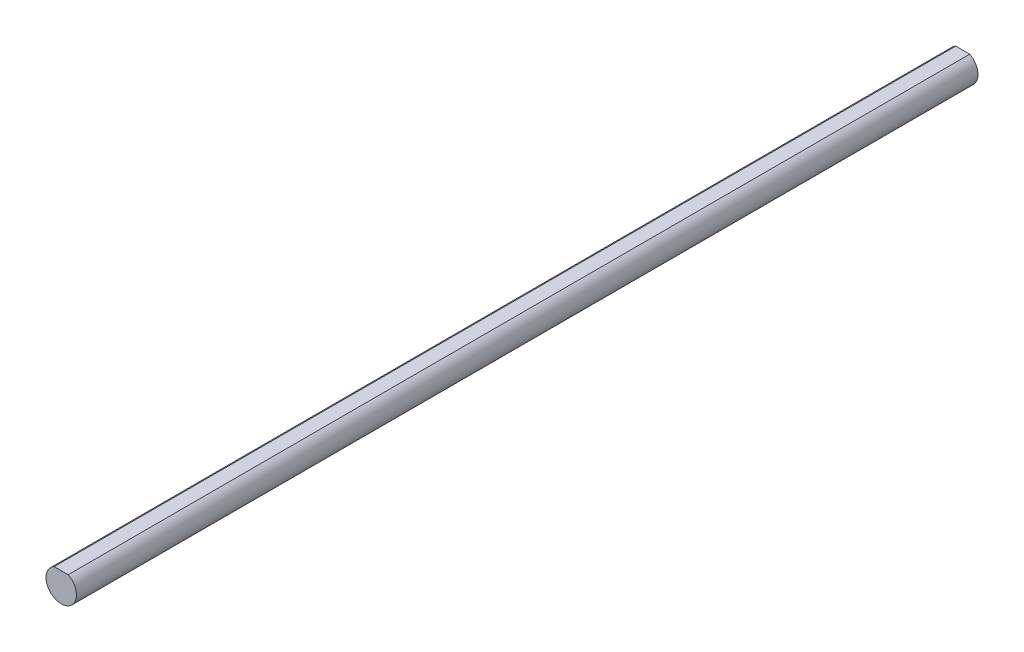
from build123d import *

# Parameters (mm, degrees)
EXTRUDE1_DEPTH = 70


with BuildPart() as part:
    # Sketch1 → Extrude1 (new body, symmetric)
    with BuildSketch(Plane.XY):
        with BuildLine():
            Line((-1.087761463, 2.1), (1.087761463, 2.1))
            ThreePointArc((1.087761463, 2.1), (0, -2.365), (-1.087761463, 2.1))
        make_face()
    extrude(amount=EXTRUDE1_DEPTH, both=True)


solid = part.part
